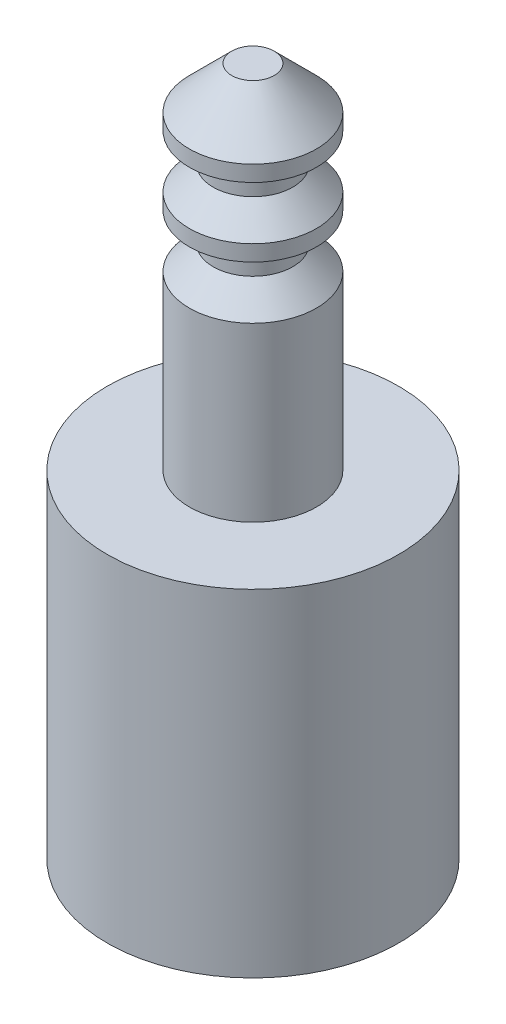
from build123d import *


with BuildPart() as part:
    # Sketch1 → Revolve1 (revolve)
    with BuildSketch(Plane.XY, mode=Mode.PRIVATE) as revolve1_sk:
        Polygon((2.75, 6.35), (1.2, 6.35), (1.2, 9.6), (0.75, 10.05), (0.75, 10.6), (1.2, 10.6), (1.2, 10.9), (0.75, 11.35), (0.75, 11.9), (1.2, 11.9), (1.2, 12.2), (0.4, 13), (0, 13), (0, 0), (2.75, 0), align=None)
    revolve(revolve1_sk.sketch.rotate(Axis((0, 0, 0), (0, -1, 0)), 180), axis=Axis((0, 0, 0), (0, -1, 0)))  # turned: the seam where the file's is


solid = part.part
